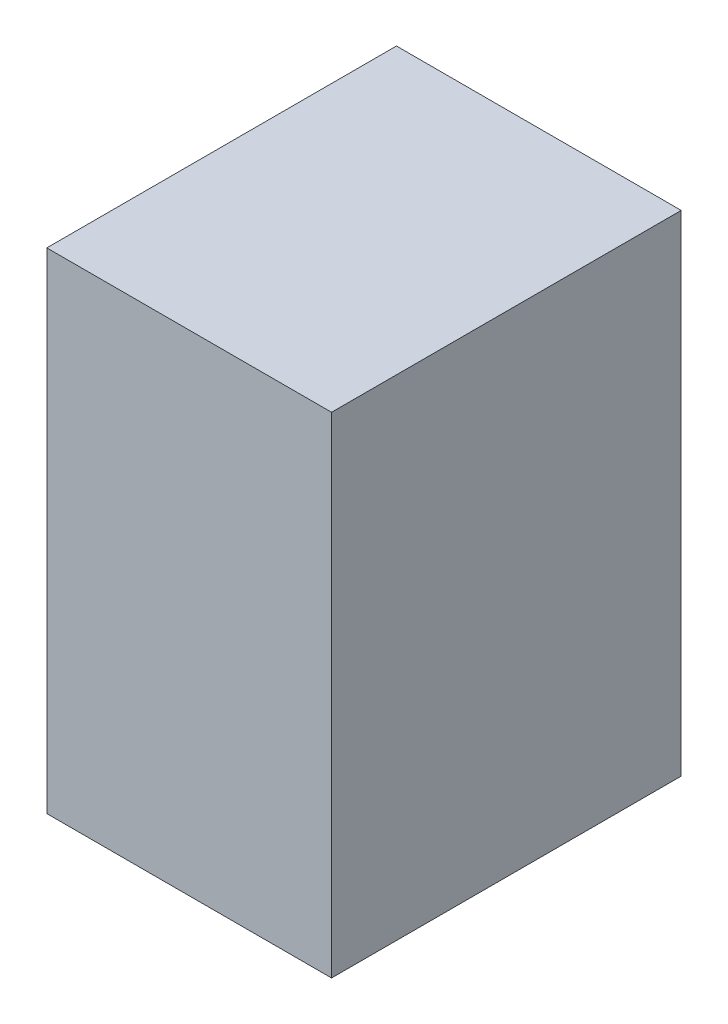
from build123d import *

# Parameters (mm, degrees)
SKETCH1_W           = 68
SKETCH1_H           = 83.5
BOSS_EXTRUDE1_DEPTH = 117


with BuildPart() as part:
    # Sketch1 → Boss-Extrude1 (new body)
    with BuildSketch(Plane(origin=(0, 0, 0), x_dir=(1, 0, 0), z_dir=(0, 1, 0))):
        with Locations((-20.808350739, 1.936386728)):
            Rectangle(SKETCH1_W, SKETCH1_H)
    extrude(amount=BOSS_EXTRUDE1_DEPTH)


solid = part.part
